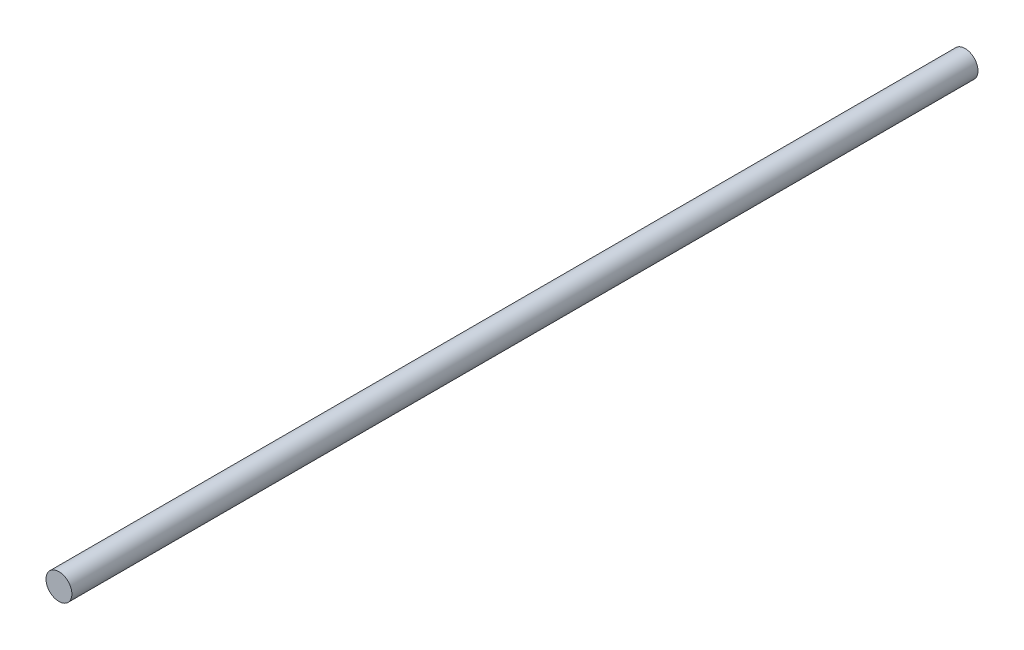
from build123d import *

# Parameters (mm, degrees)
SKETCH1_R           = 1.5
BOSS_EXTRUDE1_DEPTH = 105


with BuildPart() as part:
    # Sketch1 → Boss-Extrude1 (new body)
    with BuildSketch(Plane.XY):
        Circle(SKETCH1_R)
    extrude(amount=BOSS_EXTRUDE1_DEPTH)


solid = part.part
